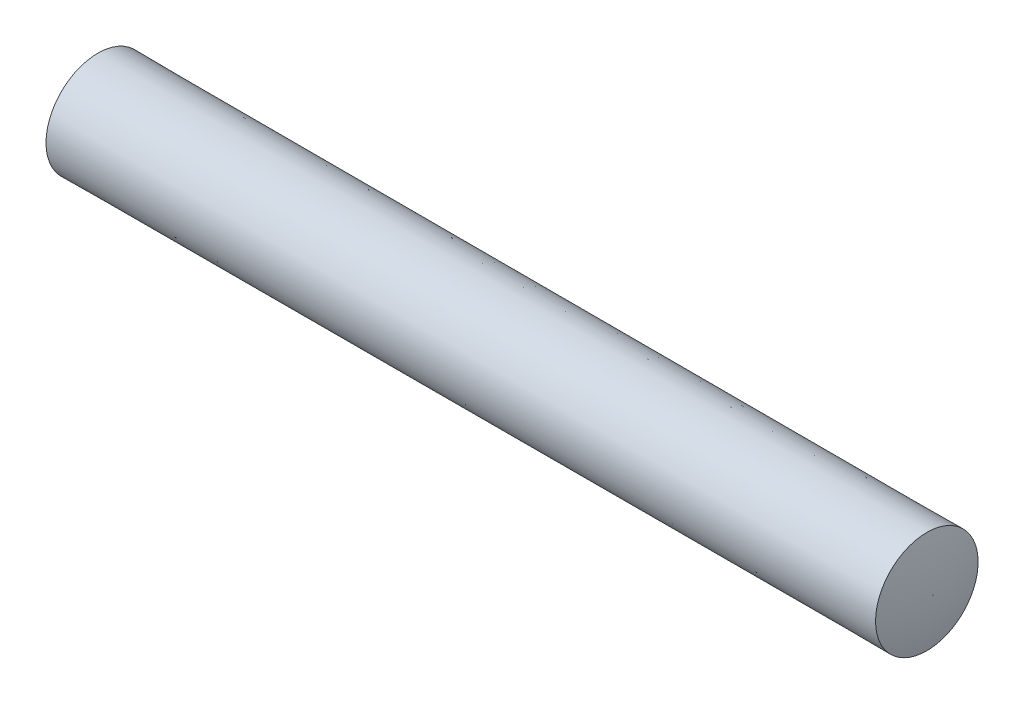
from build123d import *


with BuildPart() as part:
    # Sketch1 → Base-Revolve (revolve)
    with BuildSketch(Plane.XY):
        with BuildLine():
            Line((0, 0), (0, 0.0079375))
            ThreePointArc((0, 0.0079375), (0.024792029, 0.403935909), (0.098780938, 0.79375))
            Line((0.098780938, 0.79375), (12.798780938, 0.785481771))
            ThreePointArc((12.798780938, 0.785481771), (12.871198733, 0.399703452), (12.895461607, 0.0079375))
            Line((12.895461607, 0.0079375), (12.895461607, 0))
            Line((12.895461607, 0), (0, 0))
        make_face()
    revolve(axis=Axis((-5.588, 0, 0), (1, 0, 0)))


solid = part.part
